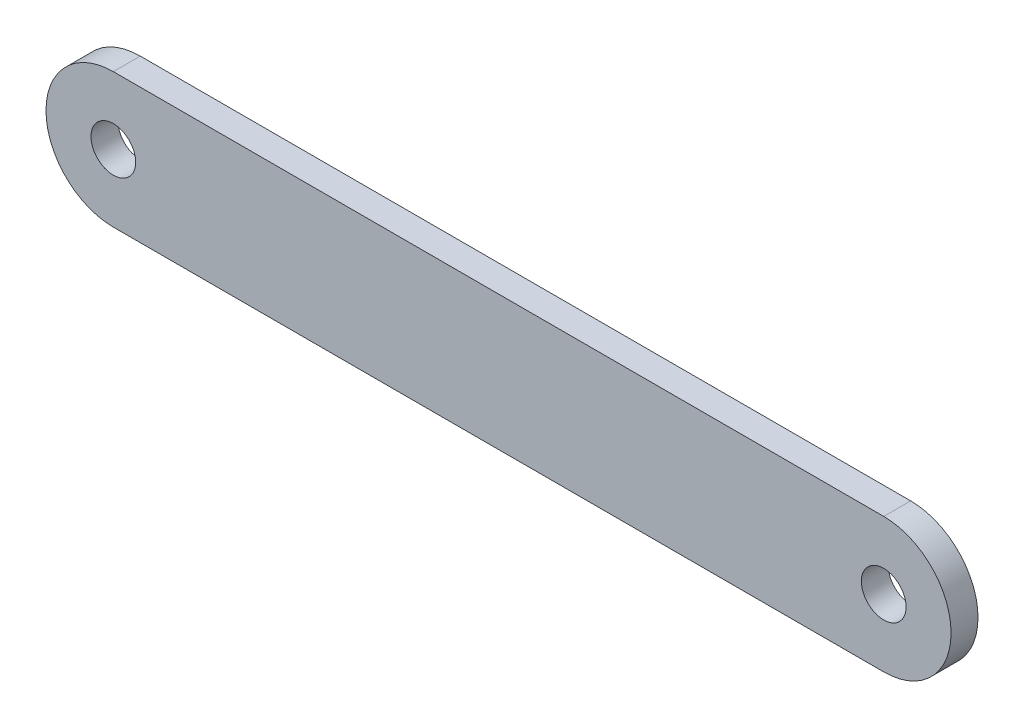
from build123d import *

# Parameters (mm, degrees)
SKICA1_R                = 4.15
P_IDAT_VYSUNUT_M1_DEPTH = 5


with BuildPart() as part:
    # Skica1 → Přidat vysunutím1 (new body)
    with BuildSketch(Plane.XY):
        with BuildLine():
            Line((0, 12.5), (143, 12.5))
            ThreePointArc((143, 12.5), (155.5, 0), (143, -12.5))
            Line((143, -12.5), (0, -12.5))
            ThreePointArc((0, -12.5), (-12.5, 0), (0, 12.5))
        make_face()
        Circle(SKICA1_R, mode=Mode.SUBTRACT)
        with Locations((143, 0)):
            Circle(SKICA1_R, mode=Mode.SUBTRACT)
    extrude(amount=P_IDAT_VYSUNUT_M1_DEPTH)


solid = part.part
